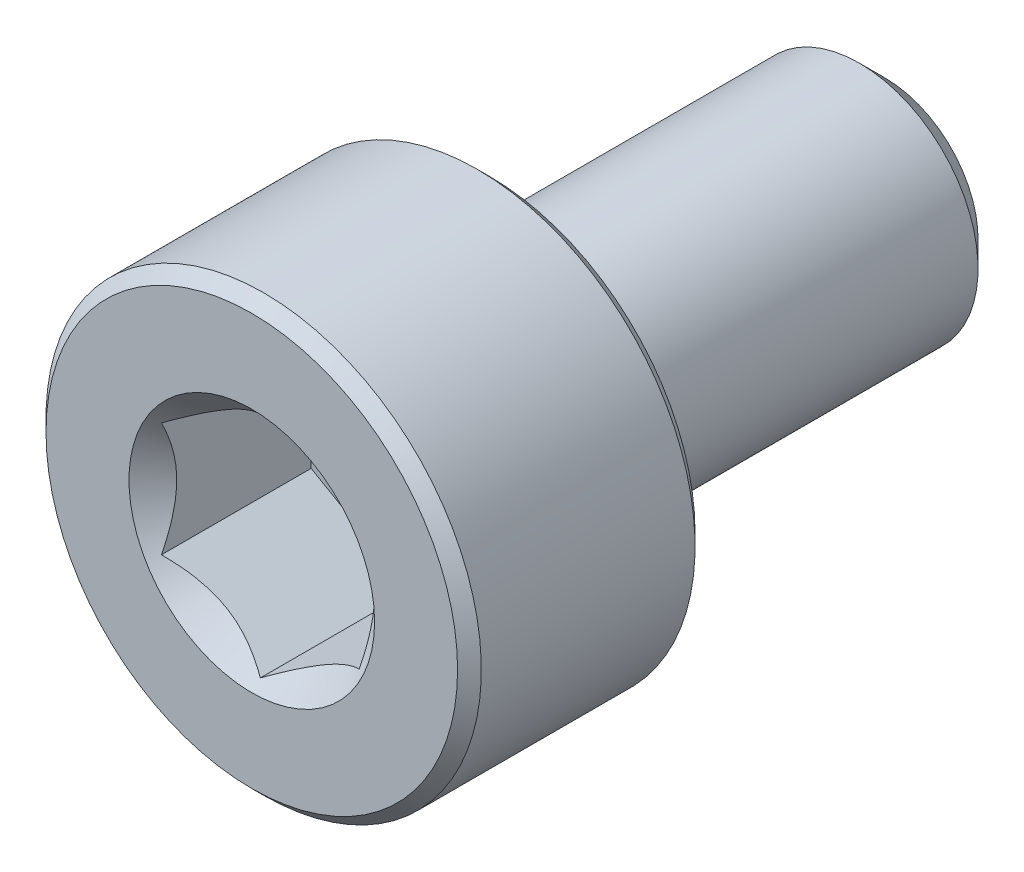
from build123d import *

# Parameters (mm, degrees)
CUT_EXTRUDE1_DEPTH = 2
SKETCH4_R          = 1.551628848
CUT_EXTRUDE2_DEPTH = 2
CUT_EXTRUDE2_DRAFT = -45


with BuildPart() as part:
    # Sketch2 → Revolve1 (revolve)
    with BuildSketch(Plane(origin=(0, 0, 0), x_dir=(0, 0, -1), z_dir=(1, 0, 0))):
        with BuildLine():
            Line((-4, 0), (-4, 2.6))
            Line((-4, 2.6), (-3.85, 2.75))
            Line((-3.85, 2.75), (-1.15, 2.75))
            Line((-1.15, 2.75), (-1, 2.6))
            Line((-1, 2.6), (-1, 1.65))
            ThreePointArc((-1, 1.65), (-0.956066017, 1.543933983), (-0.85, 1.5))
            Line((-0.85, 1.5), (3.675240474, 1.5))
            Line((3.675240474, 1.5), (4, 1.175240474))
            Line((4, 1.175240474), (4, 0))
            Line((4, 0), (-4, 0))
        make_face()
    revolve(axis=Axis((0, 0, -4), (0, 0, 1)))

    # Sketch3 → Cut-Extrude1 (cut)
    with BuildSketch(Plane.XY.offset(4)):
        Polygon((1.25, -0.721687836), (1.25, 0.721687836), (0, 1.443375673), (-1.25, 0.721687836), (-1.25, -0.721687836), (0, -1.443375673), align=None)
    extrude(amount=-CUT_EXTRUDE1_DEPTH, mode=Mode.SUBTRACT)


with BuildPart() as cut_extrude2_tool:
    # Sketch4 → Cut-Extrude2 (with draft: the straight prism first)
    with BuildSketch(Plane.XY.offset(4)):
        Circle(SKETCH4_R)
    extrude(amount=-CUT_EXTRUDE2_DEPTH)
    # Cut-Extrude2: the draft: its side faces are tilted about the plane it starts from
    cut_extrude2_sides = [cut_extrude2_tool.faces().sort_by_distance(p)[0] for p in [
        (-1.551628848, 0, 3),
    ]]
    draft(cut_extrude2_sides, Plane.XY.offset(4), CUT_EXTRUDE2_DRAFT)


with BuildPart() as part_1:
    add(part.part)

    # Cut-Extrude2: cut by cut_extrude2_tool
    add(cut_extrude2_tool.part, mode=Mode.SUBTRACT)


solid = part_1.part
